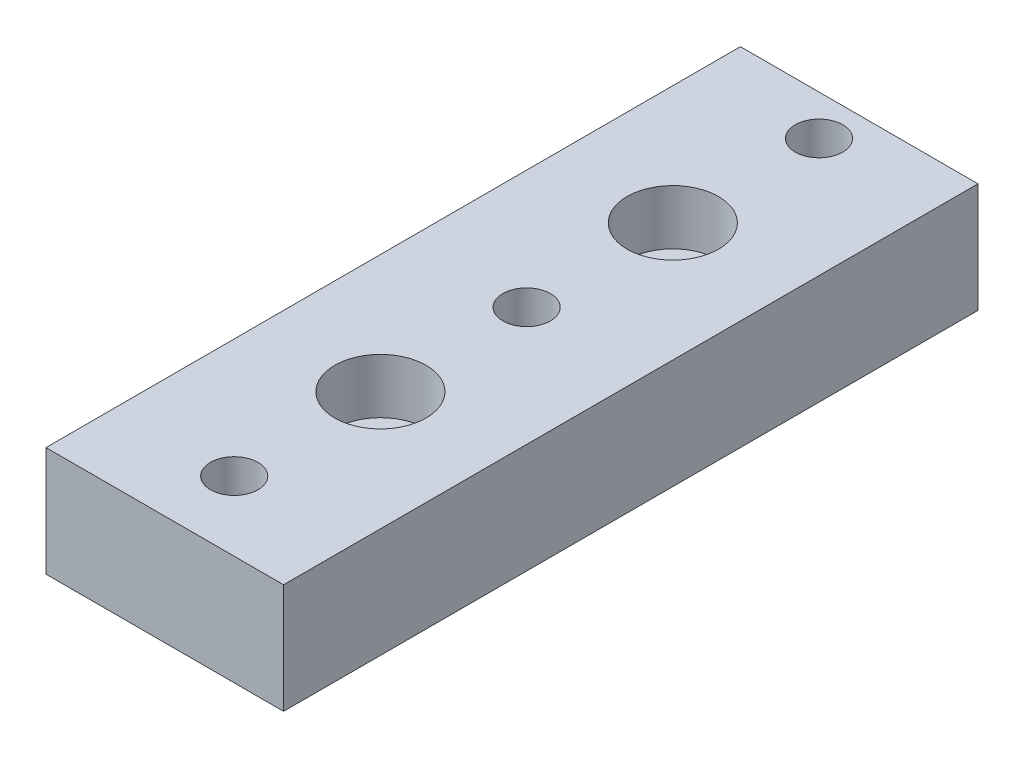
from build123d import *

# Parameters (mm, degrees)
SKETCH1_W                    = 6.5
SKETCH1_H                    = 19
BOSS_BODY_DEPTH              = 3
SKETCH2_R                    = 0.65
CUT_SCREW_HOLES_DEPTH        = 4
SKETCH4_R                    = 1.25
CUT_SCREW_HEAD_POCKETS_DEPTH = 1.5


with BuildPart() as part:
    # Sketch1 → Boss-Body (new body)
    with BuildSketch(Plane(origin=(0, 0, 0), x_dir=(1, 0, 0), z_dir=(0, 1, 0))):
        Rectangle(SKETCH1_W, SKETCH1_H)
    extrude(amount=-BOSS_BODY_DEPTH)

    # Sketch2 → Cut-Screw Holes (cut, through all)
    with BuildSketch(Plane(origin=(0, 0, 0), x_dir=(1, 0, 0), z_dir=(0, 1, 0))):
        with Locations((0, -7.6)):
            Circle(SKETCH2_R)
        with Locations((0, 0.4)):
            Circle(SKETCH2_R)
        with Locations((0, 8.4)):
            Circle(SKETCH2_R)
        with Locations((0, 4.4)):
            Circle(SKETCH2_R)
        with Locations((0, -3.6)):
            Circle(SKETCH2_R)
    extrude(amount=-CUT_SCREW_HOLES_DEPTH, mode=Mode.SUBTRACT)

    # Sketch4 → Cut-Screw Head Pockets (cut)
    with BuildSketch(Plane(origin=(0, 0, 0), x_dir=(1, 0, 0), z_dir=(0, 1, 0))):
        with Locations((0, 4.4)):
            Circle(SKETCH4_R)
        with Locations((0, -3.6)):
            Circle(SKETCH4_R)
    extrude(amount=-CUT_SCREW_HEAD_POCKETS_DEPTH, mode=Mode.SUBTRACT)


solid = part.part
